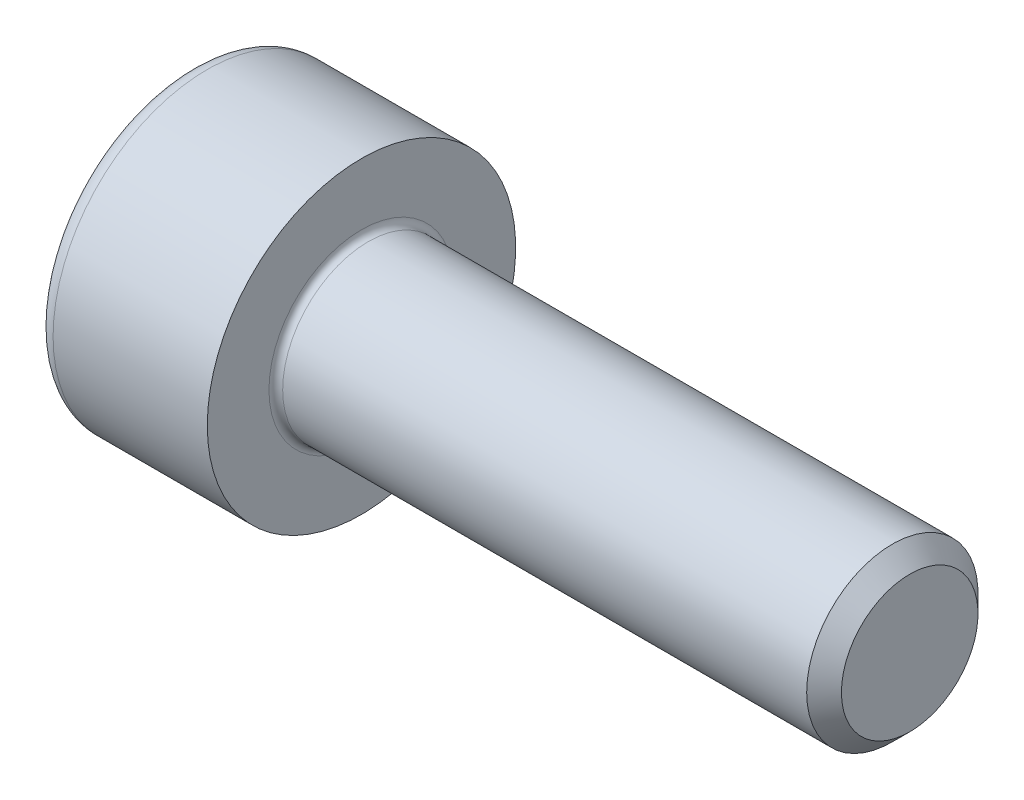
from build123d import *

# Parameters (mm, degrees)
FILLET1_R   = 0.1
FILLET2_R   = 0.25
HEX_2_DEPTH = 1.1


with BuildPart() as part:
    # BodySke → Base-Revolve (revolve)
    with BuildSketch(Plane.XY):
        Polygon((0, 0), (0, 2.25), (2.5, 2.25), (2.5, 1.25), (10.2465, 1.25), (10.5, 0.9965), (10.5, 0), align=None)
    revolve(axis=Axis((-31.75, 0, 0), (1, 0, 0)))

    # Fillet1
    fillet1_edges = [part.edges().sort_by_distance(p)[0] for p in [
        (2.5, -1.25, 0),
    ]]
    fillet(fillet1_edges, radius=FILLET1_R)

    # Fillet2
    fillet2_edges = [part.edges().sort_by_distance(p)[0] for p in [
        (0, -2.25, 0),
    ]]
    fillet(fillet2_edges, radius=FILLET2_R)

    # Sketch2 → Hex-PreBroach (revolve, cut)
    with BuildSketch(Plane.XY):
        Polygon((0, 1.01), (1.1, 1.01), (1.683123772, 0), (0, 0), align=None)
    revolve(axis=Axis((0, 0, 0), (1, 0, 0)), mode=Mode.SUBTRACT)

    # Sketch3 → Hex 2 (cut)
    with BuildSketch(Plane(origin=(0, 0, 0), x_dir=(0, 0.5, 0.866025404), z_dir=(-1, 0, 0))):
        Polygon((0.583123772, 1.01), (-0.583123772, 1.01), (-1.166247544, 0), (-0.583123772, -1.01), (0.583123772, -1.01), (1.166247544, 0), align=None)
    extrude(amount=-HEX_2_DEPTH, mode=Mode.SUBTRACT)


solid = part.part
